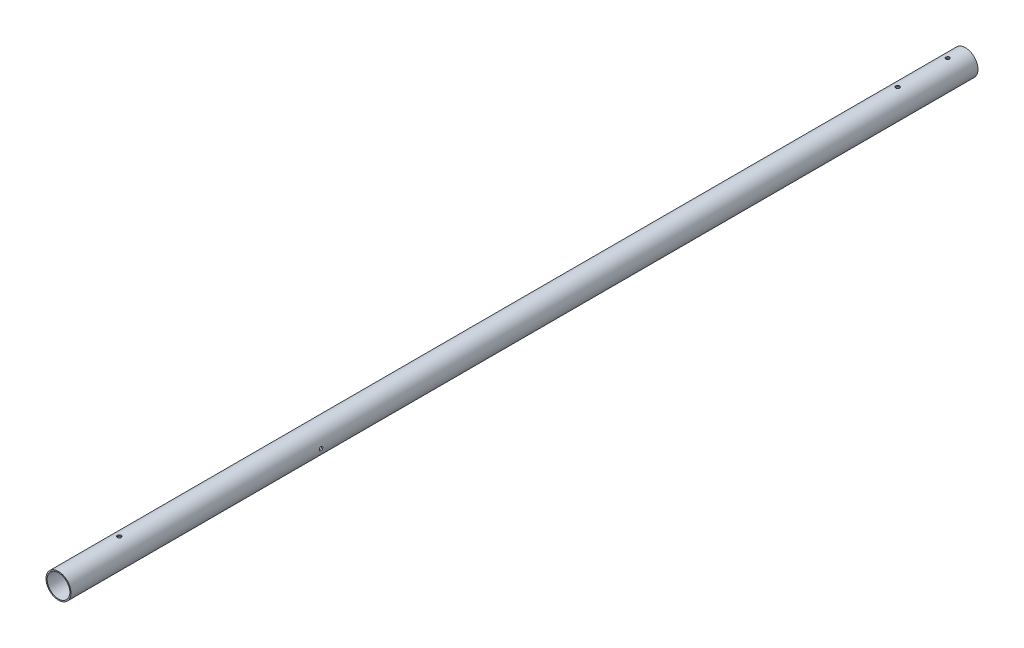
from build123d import *

# Parameters (mm, degrees)
SKETCH2_R               = 17.5
SKETCH2_R_2             = 15.9125
BOSS_EXTRUDE1_DEPTH     = 540
SKETCH6_W               = 2.75
SKETCH6_H               = 17.5
SKETCH7_R               = 17.5
SKETCH7_R_2             = 15.9125
BOSS_EXTRUDE2_DEPTH     = 130
SKETCH13_R              = 17.5
SKETCH13_R_2            = 15.9125
BOSS_EXTRUDE4_DEPTH     = 59.5
SKETCH12_R              = 2.75
CUT_EXTRUDE4_DEPTH      = 18.5000001
CUT_EXTRUDE4_DEPTH_BACK = 18.5000001
SKETCH14_R              = 2.5
CUT_EXTRUDE5_DEPTH      = 18.5000001
CUT_EXTRUDE5_DEPTH_BACK = 18.5000001
SKETCH15_R              = 2.5
CUT_EXTRUDE6_DEPTH      = 18.5000001
CUT_EXTRUDE6_DEPTH_BACK = 18.5000001


with BuildPart() as part:
    # Sketch2 → Boss-Extrude1 (new body, symmetric)
    with BuildSketch(Plane.XY):
        Circle(SKETCH2_R)
        Circle(SKETCH2_R_2, mode=Mode.SUBTRACT)
    extrude(amount=BOSS_EXTRUDE1_DEPTH, both=True)

    # Sketch6 → M5 Clearance Hole1 (revolve, cut)
    with BuildSketch(Plane(origin=(0, 0, -445), x_dir=(0, 0, -1), z_dir=(1, 0, 0))):
        with Locations((1.375, 8.75)):
            Rectangle(SKETCH6_W, SKETCH6_H)
    m5_clearance_hole1 = revolve(axis=Axis((0, -6.35, -445), (0, 1, 0)), mode=Mode.SUBTRACT)

    # Mirror1: M5 Clearance Hole1 across plane
    add(m5_clearance_hole1.mirror(Plane.ZX), mode=Mode.SUBTRACT)

    # Sketch7 → Boss-Extrude2 (add)
    with BuildSketch(Plane.XY.offset(540)):
        Circle(SKETCH7_R)
        Circle(SKETCH7_R_2, mode=Mode.SUBTRACT)
    extrude(amount=BOSS_EXTRUDE2_DEPTH)

    # Sketch13 → Boss-Extrude4 (add)
    with BuildSketch(Plane.XY.offset(670)):
        Circle(SKETCH13_R)
        Circle(SKETCH13_R_2, mode=Mode.SUBTRACT)
    extrude(amount=BOSS_EXTRUDE4_DEPTH)

    # Sketch12 → Cut-Extrude4 (cut, two sides)
    with BuildSketch(Plane(origin=(0, 0, 0), x_dir=(1, 0, 0), z_dir=(0, 1, 0))) as cut_extrude4_sk:
        with Locations((0, -644.5)):
            Circle(SKETCH12_R)
    extrude(amount=CUT_EXTRUDE4_DEPTH, mode=Mode.SUBTRACT)
    extrude(cut_extrude4_sk.sketch, amount=-CUT_EXTRUDE4_DEPTH_BACK, mode=Mode.SUBTRACT)

    # Sketch14 → Cut-Extrude5 (cut, two sides)
    with BuildSketch(Plane(origin=(0, 0, 0), x_dir=(1, 0, 0), z_dir=(0, 1, 0))) as cut_extrude5_sk:
        with Locations((0, 515)):
            Circle(SKETCH14_R)
    extrude(amount=CUT_EXTRUDE5_DEPTH, mode=Mode.SUBTRACT)
    extrude(cut_extrude5_sk.sketch, amount=-CUT_EXTRUDE5_DEPTH_BACK, mode=Mode.SUBTRACT)

    # Sketch15 → Cut-Extrude6 (cut, two sides)
    with BuildSketch(Plane(origin=(0, 0, 0), x_dir=(0, 0, -1), z_dir=(1, 0, 0))) as cut_extrude6_sk:
        with Locations((-379.5, 0)):
            Circle(SKETCH15_R)
    extrude(amount=CUT_EXTRUDE6_DEPTH, mode=Mode.SUBTRACT)
    extrude(cut_extrude6_sk.sketch, amount=-CUT_EXTRUDE6_DEPTH_BACK, mode=Mode.SUBTRACT)


solid = part.part
